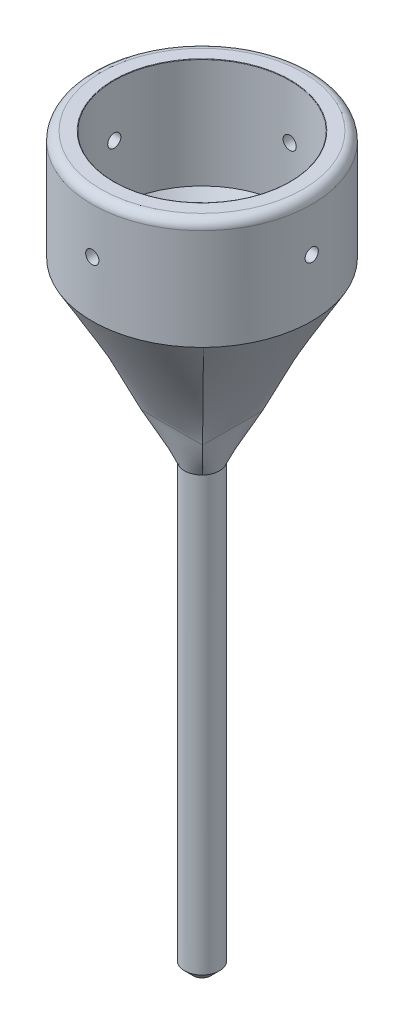
from build123d import *

# Parameters (mm, degrees)
SKETCH1_R               = 3.98
BOSS_EXTRUDE1_DEPTH     = 85
SKETCH2_R               = 3.98
BOSS_EXTRUDE2_DEPTH     = 15.5
SKETCH8_R               = 20
CUT_EXTRUDE2_DEPTH      = 15.5
CUT_EXTRUDE2_DRAFT      = -36
SKETCH9_R               = 25
SKETCH9_R_2             = 20
BOSS_EXTRUDE3_DEPTH     = 25
CUT_EXTRUDE3_DEPTH      = 30
CUT_EXTRUDE3_DEPTH_BACK = 30
SKETCH11_R              = 1.5
CUT_EXTRUDE4_DEPTH      = 30
CUT_EXTRUDE4_DEPTH_BACK = 30
SKETCH12_R              = 1.5
FILLET2_R               = 2
FILLET3_R               = 0.1
CHAMFER1_SIZE           = 2


with BuildPart() as part:
    # Sketch1 → Boss-Extrude1 (new body)
    with BuildSketch(Plane(origin=(0, 0, 0), x_dir=(1, 0, 0), z_dir=(0, 1, 0))):
        Circle(SKETCH1_R)
    extrude(amount=BOSS_EXTRUDE1_DEPTH)

    # Sketch2 → Boss-Extrude2 (add)
    with BuildSketch(Plane(origin=(0, 85, 0), x_dir=(1, 0, 0), z_dir=(0, 1, 0))):
        Circle(SKETCH2_R)
    extrude(amount=BOSS_EXTRUDE2_DEPTH)

    # Sketch5 → Loft1 section 0
    with BuildSketch(Plane(origin=(0, 110.5, 0), x_dir=(1, 0, 0), z_dir=(0, 1, 0))):
        with BuildLine():
            Line((-6.97197941, 6.841269849), (6.97197941, 6.841269849))
            Line((6.97197941, 6.841269849), (6.97197941, -6.841269849))
            Line((6.97197941, -6.841269849), (-6.97197941, -6.841269849))
            Line((-6.97197941, -6.841269849), (-6.97197941, 6.841269849))
        make_face()
    # Sketch4 for Loft1 → Loft1 section 1
    with BuildSketch(Plane(origin=(0, 100.5, 0), x_dir=(1, 0, 0), z_dir=(0, 1, 0))):
        with BuildLine():
            # circular arc as an exact rational Bezier (weights 1, cos(half-angle), 1)
            Bezier((-2.840788324, 2.787529677), (0, 5.682594209), (2.840788324, 2.787529677), weights=[1, 0.700384341, 1])
            Bezier((2.840788324, 2.787529677), (5.576057838, 0), (2.840788324, -2.787529677), weights=[1, 0.713765911, 1])
            Bezier((2.840788324, -2.787529677), (0, -5.682594209), (-2.840788324, -2.787529677), weights=[1, 0.700384341, 1])
            Bezier((-2.840788324, -2.787529677), (-5.576057838, 0), (-2.840788324, 2.787529677), weights=[1, 0.713765911, 1])
        make_face()
    loft()

    # Sketch6 for Loft2 → Loft2 section 0
    with BuildSketch(Plane(origin=(0, 140.5, 0), x_dir=(1, 0, 0), z_dir=(0, 1, 0))):
        with BuildLine():
            Bezier((-17.844147765, 17.509608521), (0, 35.694687248), (17.844147765, 17.509608521), weights=[1, 0.700384341, 1])
            Bezier((17.844147765, 17.509608521), (35.025488929, 0), (17.844147765, -17.509608521), weights=[1, 0.713765911, 1])
            Bezier((17.844147765, -17.509608521), (0, -35.694687248), (-17.844147765, -17.509608521), weights=[1, 0.700384341, 1])
            Bezier((-17.844147765, -17.509608521), (-35.025488929, 0), (-17.844147765, 17.509608521), weights=[1, 0.713765911, 1])
        make_face()
    # Sketch7 → Loft2 section 1
    with BuildSketch(Plane(origin=(0, 110.5, 0), x_dir=(1, 0, 0), z_dir=(0, 1, 0))):
        with BuildLine():
            Line((-6.97197941, 6.841269849), (6.97197941, 6.841269849))
            Line((6.97197941, 6.841269849), (6.97197941, -6.841269849))
            Line((6.97197941, -6.841269849), (-6.97197941, -6.841269849))
            Line((-6.97197941, -6.841269849), (-6.97197941, 6.841269849))
        make_face()
    loft()


with BuildPart() as cut_extrude2_tool:
    # Sketch8 → Cut-Extrude2 (with draft: the straight prism first)
    with BuildSketch(Plane(origin=(0, 140.5, 0), x_dir=(1, 0, 0), z_dir=(0, 1, 0))):
        Circle(SKETCH8_R)
    extrude(amount=-CUT_EXTRUDE2_DEPTH)
    # Cut-Extrude2: the draft: its side faces are tilted about the plane it starts from
    cut_extrude2_sides = [cut_extrude2_tool.faces().sort_by_distance(p)[0] for p in [
        (-20, 132.75, 0),
    ]]
    draft(cut_extrude2_sides, Plane(origin=(0, 140.5, 0), x_dir=(1, 0, 0), z_dir=(0, 1, 0)), CUT_EXTRUDE2_DRAFT)


with BuildPart() as part_1:
    add(part.part)

    # Cut-Extrude2: cut by cut_extrude2_tool
    add(cut_extrude2_tool.part, mode=Mode.SUBTRACT)

    # Sketch9 → Boss-Extrude3 (add)
    with BuildSketch(Plane(origin=(0, 140.5, 0), x_dir=(1, 0, 0), z_dir=(0, 1, 0))):
        Circle(SKETCH9_R)
        Circle(SKETCH9_R_2, mode=Mode.SUBTRACT)
    extrude(amount=BOSS_EXTRUDE3_DEPTH)

    # Sketch11 → Cut-Extrude3 (cut, two sides: drawn at the far end of the back side and taken through both)
    with BuildSketch(Plane(origin=(0, 0, 0), x_dir=(0, 0, -1), z_dir=(1, 0, 0)).offset(-CUT_EXTRUDE3_DEPTH_BACK)):
        with Locations((0, 153.583337253)):
            Circle(SKETCH11_R)
    extrude(amount=CUT_EXTRUDE3_DEPTH + CUT_EXTRUDE3_DEPTH_BACK, mode=Mode.SUBTRACT)

    # Sketch12 → Cut-Extrude4 (cut, two sides: drawn at the far end of the back side and taken through both)
    with BuildSketch(Plane.XY.offset(-CUT_EXTRUDE4_DEPTH_BACK)):
        with Locations((0, 153.141524967)):
            Circle(SKETCH12_R)
    extrude(amount=CUT_EXTRUDE4_DEPTH + CUT_EXTRUDE4_DEPTH_BACK, mode=Mode.SUBTRACT)

    # Fillet2
    fillet2_edges = [part_1.edges().sort_by_distance(p)[0] for p in [
        (-25, 165.5, 0),
    ]]
    fillet(fillet2_edges, radius=FILLET2_R)

    # Fillet3
    fillet3_edges = [part_1.edges().sort_by_distance(p)[0] for p in [
        (-20, 165.5, 0),
    ]]
    fillet(fillet3_edges, radius=FILLET3_R)

    # Chamfer1
    chamfer1_edges = [part_1.edges().sort_by_distance(p)[0] for p in [
        (-3.98, 0, 0),
    ]]
    chamfer(chamfer1_edges, length=CHAMFER1_SIZE)


solid = part_1.part
